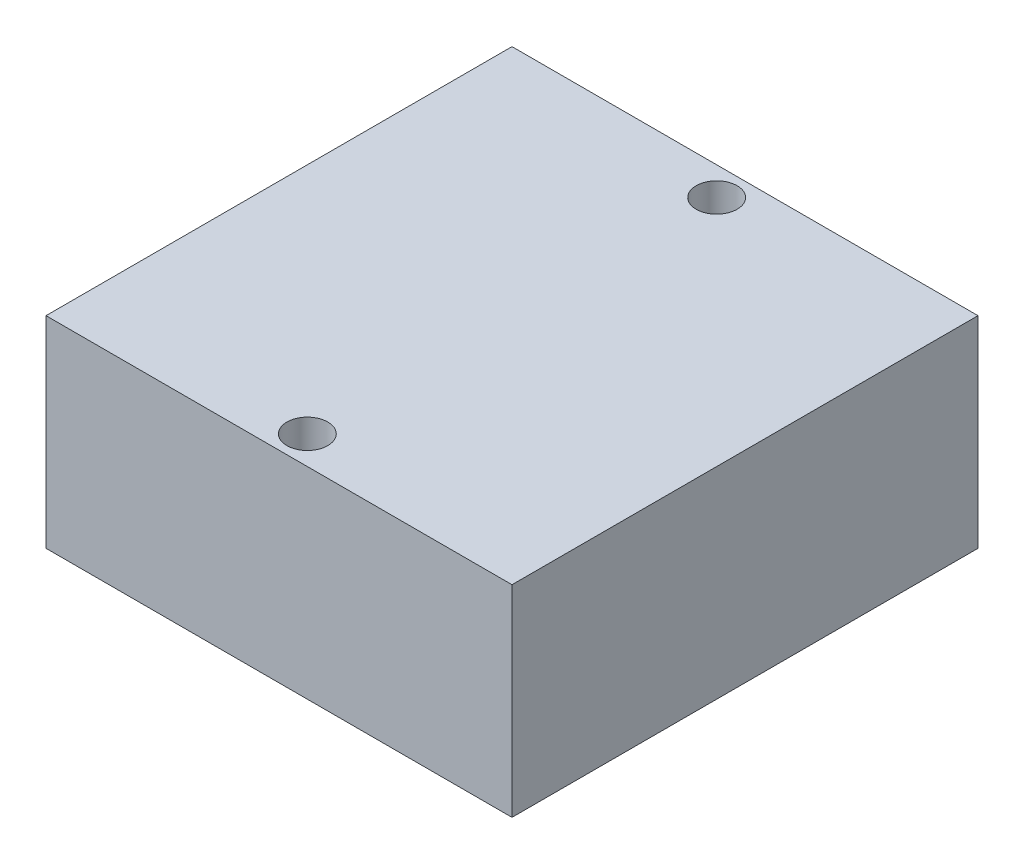
from build123d import *

# Parameters (mm, degrees)
SKETCH_1_W          = 74
SKETCH_1_H          = 74
EXTRUDE_1_DEPTH     = 32
SKETCH_2_R          = 3.25
CUT_EXTRUDE_1_DEPTH = 33


with BuildPart() as part:
    # 草图1 → 凸台-拉伸1 (new body)
    with BuildSketch(Plane(origin=(0, 0, 0), x_dir=(1, 0, 0), z_dir=(0, 1, 0))):
        Rectangle(SKETCH_1_W, SKETCH_1_H)
    extrude(amount=EXTRUDE_1_DEPTH)

    # 草图2 → 切除-拉伸1 (cut, through all)
    with BuildSketch(Plane(origin=(0, 32, 0), x_dir=(1, 0, 0), z_dir=(0, 1, 0))):
        with Locations((0, 32.5)):
            Circle(SKETCH_2_R)
        with Locations((0, -32.5)):
            Circle(SKETCH_2_R)
    extrude(amount=-CUT_EXTRUDE_1_DEPTH, mode=Mode.SUBTRACT)


solid = part.part
